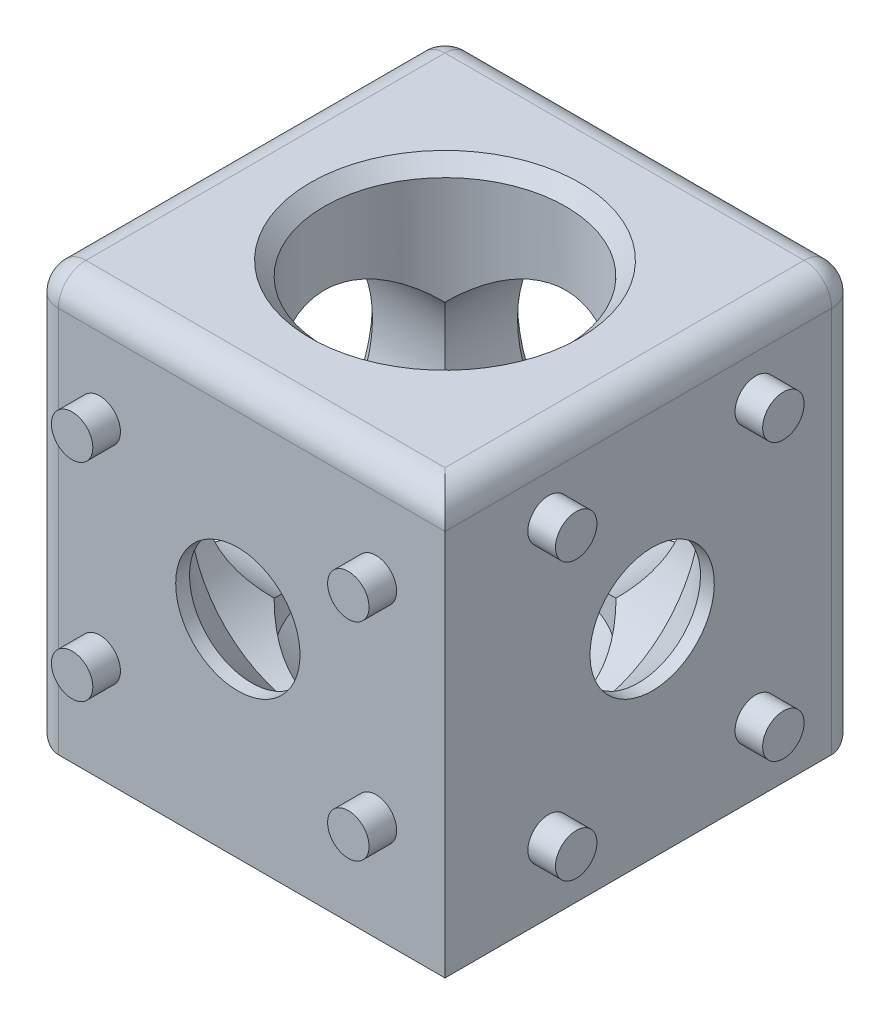
from build123d import *

# Parameters (mm, degrees)
SKETCH_1_W      = 30
SKETCH_1_H      = 30
EXTRUDE_1_DEPTH = 15
SKETCH_5_R      = 1.5
EXTRUDE_2_DEPTH = 2
FILLET_1_R      = 2


with BuildPart() as part:
    # Эскиз1 → Бобышка-Вытянуть1 (new body, symmetric)
    with BuildSketch(Plane(origin=(0, 0, 0), x_dir=(1, 0, 0), z_dir=(0, 1, 0))):
        Rectangle(SKETCH_1_W, SKETCH_1_H)
    extrude(amount=EXTRUDE_1_DEPTH, both=True)

    # Эскиз4 → Вырез-Повернуть1 (revolve, cut)
    with BuildSketch(Plane.XY):
        Polygon((-4.5, -15), (-4.5, -14), (-8.75, -9.75), (-8.75, 14), (-9.75, 15), (0, 15), (0, -15), align=None)
    cut_revolve_1 = revolve(axis=Axis((0, 15, 0), (0, -1, 0)), mode=Mode.SUBTRACT)

    # Эскиз5 → Бобышка-Вытянуть2 (add)
    with BuildSketch(Plane.XZ.offset(15)):
        with Locations(Location((-10, 7.5, 0), (0, 0, 270))):  # turned: the seam where the file's is
            Circle(SKETCH_5_R)
        with Locations(Location((-10, -7.5, 0), (0, 0, 270))):  # turned: the seam where the file's is
            Circle(SKETCH_5_R)
        with Locations(Location((10, -7.5, 0), (0, 0, 270))):  # turned: the seam where the file's is
            Circle(SKETCH_5_R)
        with Locations(Location((10, 7.5, 0), (0, 0, 270))):  # turned: the seam where the file's is
            Circle(SKETCH_5_R)
    extrude_2 = extrude(amount=EXTRUDE_2_DEPTH)

    # Зеркальное отражение1: Вырез-Повернуть1, Бобышка-Вытянуть2 across plane
    add(cut_revolve_1.mirror(Plane(origin=(0, 0, 0), x_dir=(0, 0, 1), z_dir=(0.707106781, 0.707106781, 0))), mode=Mode.SUBTRACT)
    add(extrude_2.mirror(Plane(origin=(0, 0, 0), x_dir=(0, 0, 1), z_dir=(0.707106781, 0.707106781, 0))))

    # Скругление1
    fillet_1_edges = [part.edges().sort_by_distance(p)[0] for p in [
        (-15, 15, 0),
        (0, 15, 15),
        (15, 15, 0),
        (-15, -15, 0),
        (0, -15, -15),
        (-15, 0, 15),
        (-15, 0, -15),
        (15, 0, -15),
        (0, 15, -15),
    ]]
    fillet(fillet_1_edges, radius=FILLET_1_R)

    # Зеркальное отражение2: Вырез-Повернуть1, Бобышка-Вытянуть2 across plane
    add(cut_revolve_1.mirror(Plane(origin=(0, 0, 0), x_dir=(0, -0.707106781, 0.707106781), z_dir=(0, 0.707106781, 0.707106781))), mode=Mode.SUBTRACT)
    add(extrude_2.mirror(Plane(origin=(0, 0, 0), x_dir=(0, -0.707106781, 0.707106781), z_dir=(0, 0.707106781, 0.707106781))))


solid = part.part
